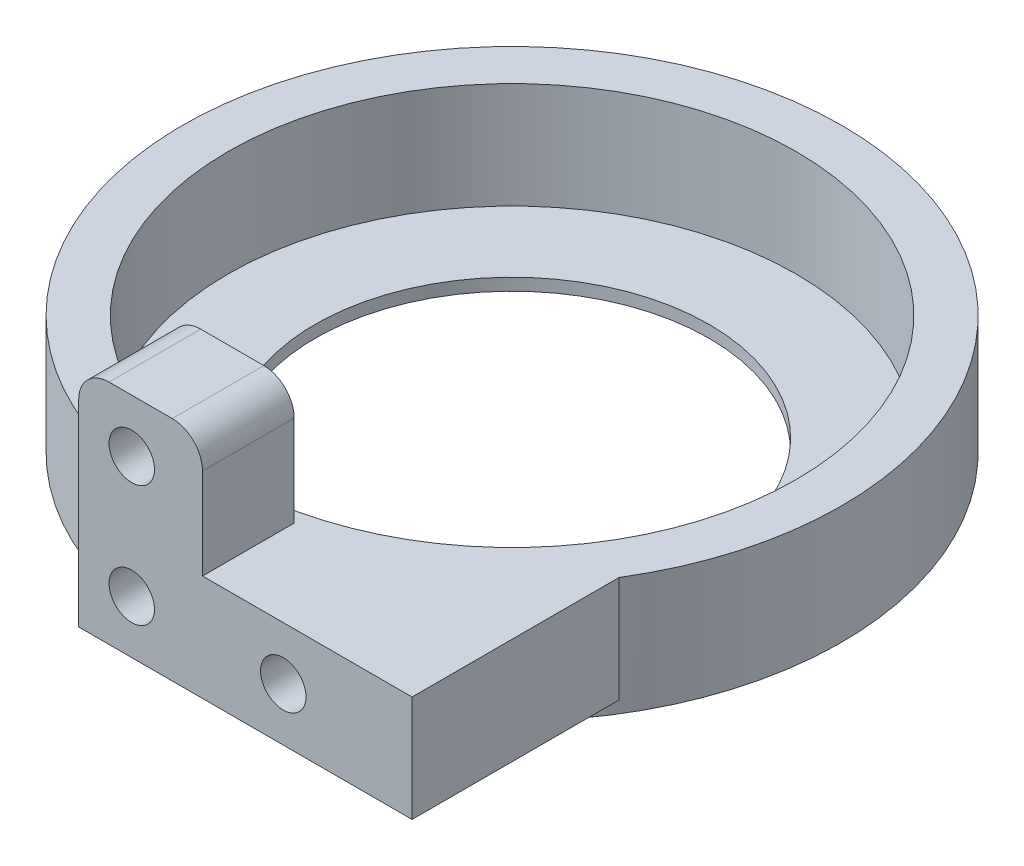
from build123d import *

# Parameters (mm, degrees)
SKETCH1_R           = 18.75
BOSS_EXTRUDE1_DEPTH = 7
SKETCH2_R           = 1.5
CUT_EXTRUDE1_DEPTH  = 7
SKETCH3_R           = 21.75
SKETCH3_R_2         = 13
BOSS_EXTRUDE2_DEPTH = 0.8
SKETCH5_W           = 3.633456263
SKETCH5_H           = 7
BOSS_EXTRUDE4_DEPTH = 15
BOSS_EXTRUDE5_DEPTH = 7
SKETCH7_R           = 1.5
CUT_EXTRUDE2_DEPTH  = 6
SKETCH8_W           = 8.171206901
SKETCH8_H           = 6.05024239
BOSS_EXTRUDE6_DEPTH = 8
SKETCH9_R           = 1.5
CUT_EXTRUDE3_DEPTH  = 10
FILLET1_R           = 2


with BuildPart() as part:
    # Sketch1 → Boss-Extrude1 (new body)
    with BuildSketch(Plane(origin=(0, 0, 0), x_dir=(1, 0, 0), z_dir=(0, 1, 0))):
        with BuildLine():
            Line((3.5, -25.1), (-3.5, -25.1))
            Line((-3.5, -25.1), (-3.5, -21.466543737))
            ThreePointArc((-3.5, -21.466543737), (0, 21.75), (3.5, -21.466543737))
            Line((3.5, -21.466543737), (3.5, -25.1))
        make_face()
        Circle(SKETCH1_R, mode=Mode.SUBTRACT)
    extrude(amount=BOSS_EXTRUDE1_DEPTH)

    # Sketch2 → Cut-Extrude1 (cut)
    with BuildSketch(Plane.XY.offset(25.1)):
        with Locations((0, 3.5)):
            Circle(SKETCH2_R)
    extrude(amount=-CUT_EXTRUDE1_DEPTH, mode=Mode.SUBTRACT)

    # Sketch3 → Boss-Extrude2 (add)
    with BuildSketch(Plane.XZ):
        Circle(SKETCH3_R)
        Circle(SKETCH3_R_2, mode=Mode.SUBTRACT)
    extrude(amount=BOSS_EXTRUDE2_DEPTH)

    # Sketch5 → Boss-Extrude4 (add)
    with BuildSketch(Plane(origin=(3.5, 0, 0), x_dir=(0, 0, -1), z_dir=(1, 0, 0))):
        with Locations((-23.283271869, 3.5)):
            Rectangle(SKETCH5_W, SKETCH5_H)
    extrude(amount=BOSS_EXTRUDE4_DEPTH)

    # Sketch6 → Boss-Extrude5 (add)
    with BuildSketch(Plane(origin=(0, 7, 0), x_dir=(1, 0, 0), z_dir=(0, 1, 0))):
        Polygon((18.5, -25.1), (18.5, -11.437329234), (3.5, -21.466543737), (3.5, -25.1), align=None)
    extrude(amount=-BOSS_EXTRUDE5_DEPTH)

    # Sketch7 → Cut-Extrude2 (cut)
    with BuildSketch(Plane.XY.offset(25.1)):
        with Locations((10, 3.5)):
            Circle(SKETCH7_R)
    extrude(amount=-CUT_EXTRUDE2_DEPTH, mode=Mode.SUBTRACT)

    # Sketch8 → Boss-Extrude6 (add)
    with BuildSketch(Plane(origin=(0, 7, 0), x_dir=(1, 0, 0), z_dir=(0, 1, 0))):
        with Locations((0.585603451, -22.074878805)):
            Rectangle(SKETCH8_W, SKETCH8_H)
    extrude(amount=BOSS_EXTRUDE6_DEPTH)

    # Sketch9 → Cut-Extrude3 (cut)
    with BuildSketch(Plane.XY.offset(25.1)):
        with Locations((0, 11.5)):
            Circle(SKETCH9_R)
    extrude(amount=-CUT_EXTRUDE3_DEPTH, mode=Mode.SUBTRACT)

    # Fillet1
    fillet1_edges = [part.edges().sort_by_distance(p)[0] for p in [
        (-3.5, 15, 22.074878805),
        (4.671206901, 15, 22.074878805),
    ]]
    fillet(fillet1_edges, radius=FILLET1_R)


solid = part.part
